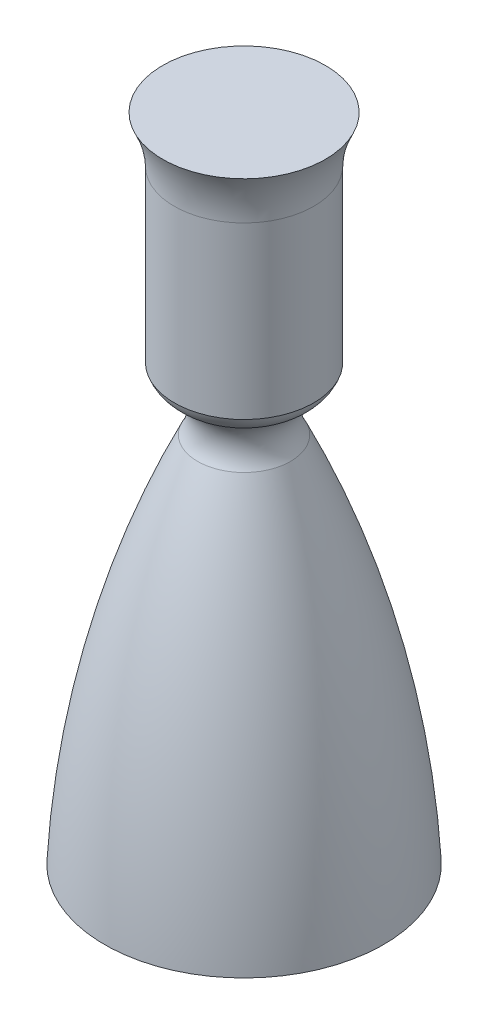
from build123d import *


with BuildPart() as part:
    # Sketch1 → Revolve1 (revolve)
    with BuildSketch(Plane.XY):
        with BuildLine():
            Line((0, 0), (76.2, 0))
            ThreePointArc((76.2, 0), (60.649726251, 104.062431563), (25.4, 203.2))
            ThreePointArc((25.4, 203.2), (22.534683015, 215.420959495), (28.139739557, 226.65239901))
            ThreePointArc((28.139739557, 226.65239901), (34.220669924, 230.899835334), (38.1, 237.221957416))
            Line((38.1, 237.221957416), (38.1, 330.2))
            ThreePointArc((38.1, 330.2), (39.804842701, 343.267539325), (44.45, 355.6))
            Line((44.45, 355.6), (0, 355.6))
            Line((0, 355.6), (0, 0))
        make_face()
    revolve(axis=Axis((0, 0, 0), (0, 1, 0)))


solid = part.part
